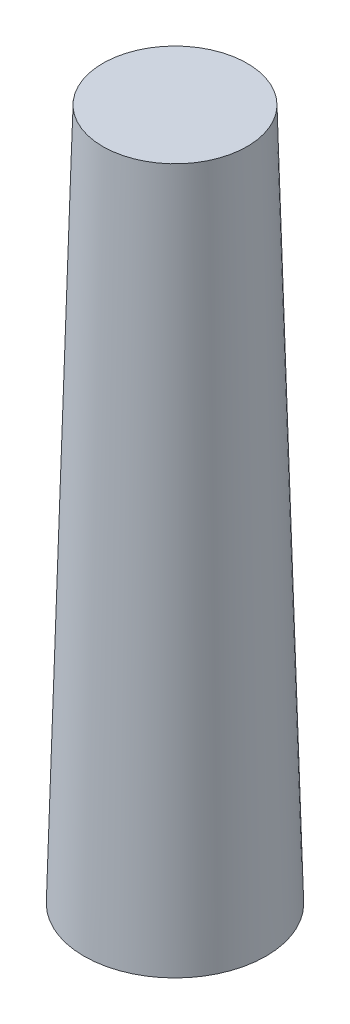
from build123d import *


with BuildPart() as part:
    # Skica1 → Rotovat1 (revolve)
    with BuildSketch(Plane.XY):
        Polygon((-5.5, 0), (-4, 55), (0, 55), (0, 57), (-5.945454545, 57), (-7.5, 0), align=None)
    revolve(axis=Axis((0, 59.344368743, 0), (0, -1, 0)))


solid = part.part
